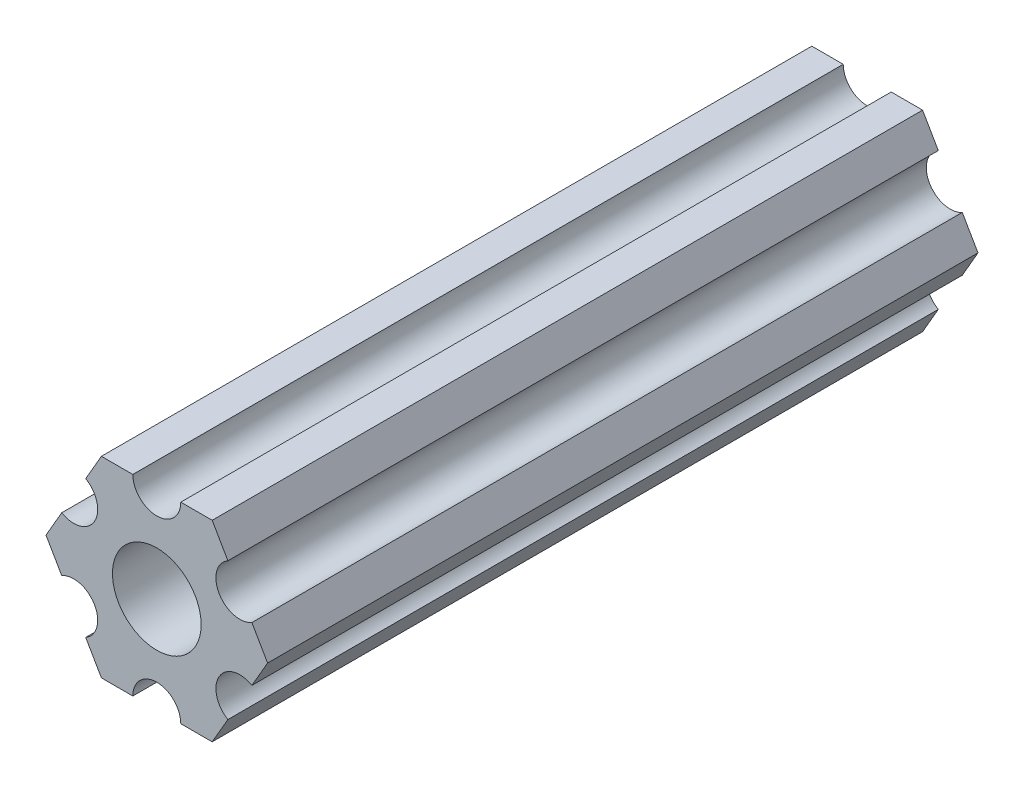
from build123d import *

# Parameters (mm, degrees)
SKETCH1_R           = 2.9337
BOSS_EXTRUDE1_DEPTH = 47.0154


with BuildPart() as part:
    # Sketch1 → Boss-Extrude1 (new body)
    with BuildSketch(Plane(origin=(0, 0, 0), x_dir=(-1, 0, 0), z_dir=(0, 0, -1))):
        with BuildLine():
            Line((-4.705511279, -4.549815428), (-3.666174225, -6.350000147))
            Line((-3.666174225, -6.350000147), (-1.5875, -6.350000147))
            ThreePointArc((-1.5875, -6.350000147), (0, -4.762500147), (1.5875, -6.350000147))
            Line((1.5875, -6.350000147), (3.666174225, -6.350000147))
            Line((3.666174225, -6.350000147), (4.705511279, -4.549815428))
            ThreePointArc((4.705511279, -4.549815428), (4.124445879, -2.381250118), (6.293011189, -1.800184719))
            Line((6.293011189, -1.800184719), (7.332348243, 0))
            Line((7.332348243, 0), (6.293011189, 1.800184719))
            ThreePointArc((6.293011189, 1.800184719), (4.124445879, 2.381250118), (4.705511279, 4.549815428))
            Line((4.705511279, 4.549815428), (3.666174225, 6.350000147))
            Line((3.666174225, 6.350000147), (1.5875, 6.350000147))
            ThreePointArc((1.5875, 6.350000147), (0, 4.762500147), (-1.5875, 6.350000147))
            Line((-1.5875, 6.350000147), (-3.666174225, 6.350000147))
            Line((-3.666174225, 6.350000147), (-4.705511279, 4.549815428))
            ThreePointArc((-4.705511279, 4.549815428), (-4.124445879, 2.381250118), (-6.293011189, 1.800184719))
            Line((-6.293011189, 1.800184719), (-7.332348243, 0))
            Line((-7.332348243, 0), (-6.293011189, -1.800184719))
            ThreePointArc((-6.293011189, -1.800184719), (-4.124445879, -2.381250118), (-4.705511279, -4.549815428))
        make_face()
        Circle(SKETCH1_R, mode=Mode.SUBTRACT)
    extrude(amount=-BOSS_EXTRUDE1_DEPTH)


solid = part.part
